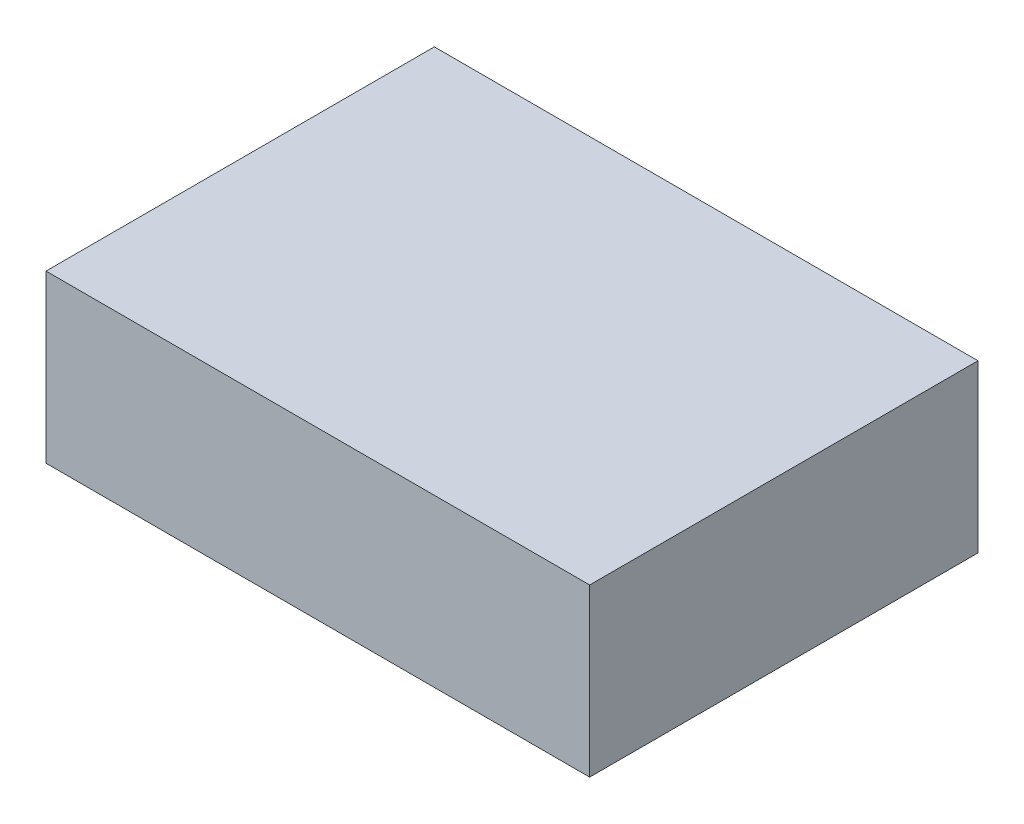
from build123d import *

# Parameters (mm, degrees)
SKETCH1_W           = 124.46
SKETCH1_H           = 88.9
BOSS_EXTRUDE1_DEPTH = 38.1


with BuildPart() as part:
    # Sketch1 → Boss-Extrude1 (new body)
    with BuildSketch(Plane(origin=(0, 0, 0), x_dir=(1, 0, 0), z_dir=(0, 1, 0))):
        with Locations((62.23, 44.45)):
            Rectangle(SKETCH1_W, SKETCH1_H)
    extrude(amount=BOSS_EXTRUDE1_DEPTH)


solid = part.part
